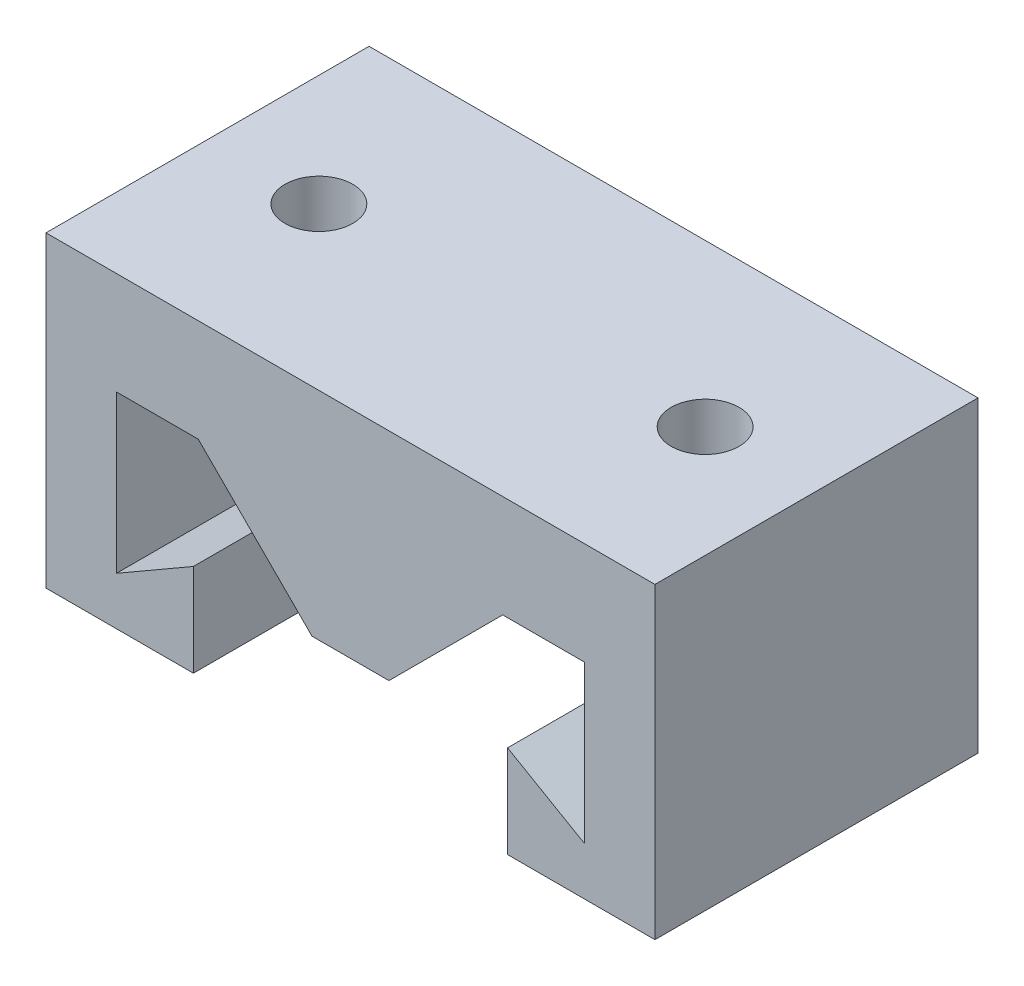
from build123d import *

# Parameters (mm, degrees)
BOSS_EXTRUDE1_DEPTH     = 10
SKETCH2_R               = 2.1
CUT_EXTRUDE1_DEPTH      = 6.35
SKETCH3_W               = 9.725
SKETCH3_H               = 19.05
CUT_EXTRUDE2_DEPTH      = 11
CUT_EXTRUDE2_DEPTH_BACK = 11


with BuildPart() as part:
    # Sketch1 → Boss-Extrude1 (new body, symmetric)
    with BuildSketch(Plane.XY):
        Polygon((9.725, 0), (19.05, 0), (19.05, 19.05), (-19.05, 19.05), (-19.05, 0), (-9.725, 0), (-9.725, 5.724630657), (-14.4875, 2.975), (-14.4875, 12.7), (-9.425, 12.7), (-2.38125, 5.65625), (2.38125, 5.65625), (9.425, 12.7), (14.4875, 12.7), (14.4875, 2.975), (9.725, 5.724630657), align=None)
    extrude(amount=BOSS_EXTRUDE1_DEPTH, both=True)

    # Sketch2 → Cut-Extrude1 (cut)
    with BuildSketch(Plane(origin=(0, 19.05, 0), x_dir=(1, 0, 0), z_dir=(0, 1, 0))):
        with Locations((-11.95625, 0)):
            Circle(SKETCH2_R)
        with Locations((11.95625, 0)):
            Circle(SKETCH2_R)
    extrude(amount=-CUT_EXTRUDE1_DEPTH, mode=Mode.SUBTRACT)

    # Sketch3 → Cut-Extrude2 (cut, two sides)
    with BuildSketch(Plane.XY) as cut_extrude2_sk:
        with Locations((-23.7125, 9.525)):
            Rectangle(SKETCH3_W, SKETCH3_H)
        with Locations((23.7125, 9.525)):
            Rectangle(SKETCH3_W, SKETCH3_H)
    extrude(amount=CUT_EXTRUDE2_DEPTH, mode=Mode.SUBTRACT)
    extrude(cut_extrude2_sk.sketch, amount=-CUT_EXTRUDE2_DEPTH_BACK, mode=Mode.SUBTRACT)


solid = part.part
